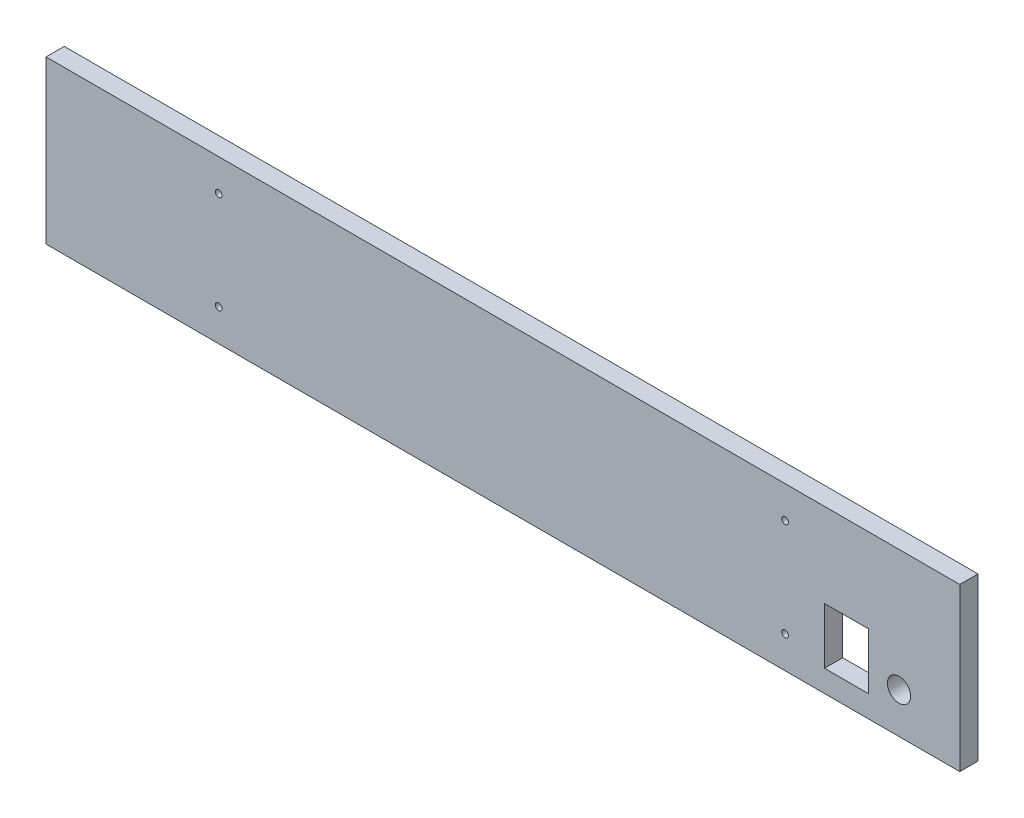
from build123d import *

# Parameters (mm, degrees)
SZKIC1_W                    = 451
SZKIC1_H                    = 80
DODANIE_WYCI_GNI_CIE1_DEPTH = 9
SZKIC2_W                    = 21.8
SZKIC2_H                    = 27.7
SZKIC2_R                    = 5.75
SZKIC2_R_2                  = 1.65
WYTNIJ_WYCI_GNI_CIE1_DEPTH  = 10


with BuildPart() as part:
    # Szkic1 → Dodanie-wyciągnięcie1 (new body)
    with BuildSketch(Plane.XY):
        with Locations((225.5, 40)):
            Rectangle(SZKIC1_W, SZKIC1_H)
    extrude(amount=-DODANIE_WYCI_GNI_CIE1_DEPTH)

    # Szkic2 → Wytnij-wyciągnięcie1 (cut)
    with BuildSketch(Plane.XY):
        with Locations((395.1, 24.64)):
            Rectangle(SZKIC2_W, SZKIC2_H)
        with Locations((421, 20)):
            Circle(SZKIC2_R)
        with Locations((364.78, 64.21)):
            Circle(SZKIC2_R_2)
        with Locations((364.78, 15.79)):
            Circle(SZKIC2_R_2)
        with Locations((85.22, 64.21)):
            Circle(SZKIC2_R_2)
        with Locations((85.22, 15.79)):
            Circle(SZKIC2_R_2)
    extrude(amount=-WYTNIJ_WYCI_GNI_CIE1_DEPTH, mode=Mode.SUBTRACT)


solid = part.part
